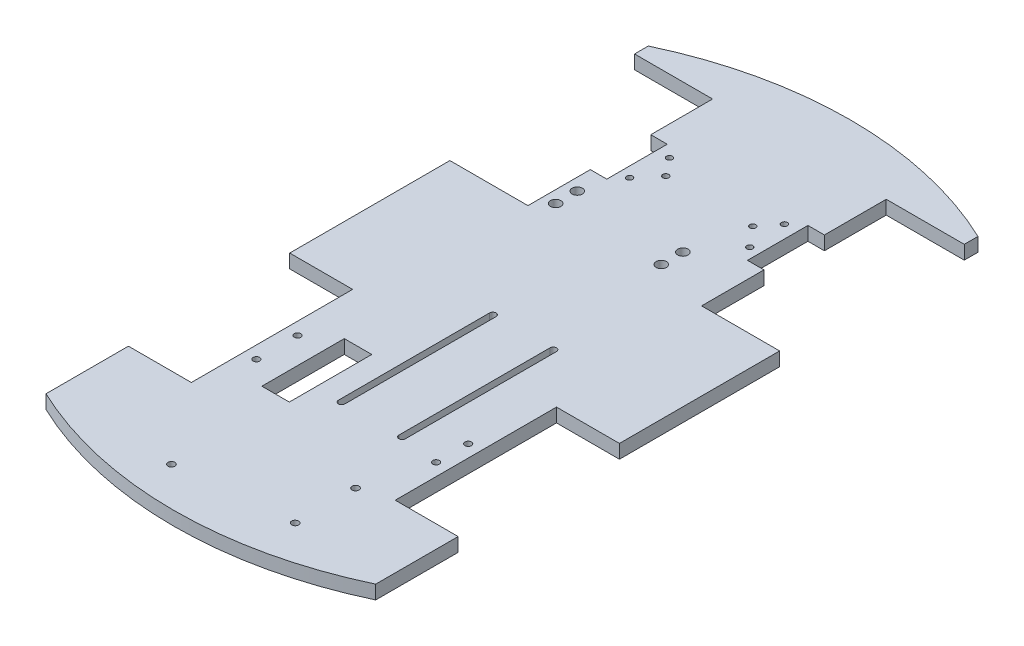
from build123d import *

# Parameters (mm, degrees)
CHASSIS_DEPTH       = 6.35
BOSS_EXTRUDE1_DEPTH = 6.35
SKETCH2_R           = 1.5875
SKETCH2_R_2         = 1.5
SKETCH2_R_3         = 1.3716
SKETCH2_R_4         = 2.38125
SKETCH2_W           = 12.7
SKETCH2_H           = 38.1
CUT_EXTRUDE1_DEPTH  = 17.78


with BuildPart() as part:
    # Sketch1 → Chassis (new body)
    with BuildSketch(Plane(origin=(0, 0, 0), x_dir=(1, 0, 0), z_dir=(0, 1, 0))):
        with BuildLine():
            Line((0, 66.173750115), (0, -229.362))
            Line((0, -229.362), (76.2, -229.362))
            Line((76.2, -229.362), (76.2, -191.262))
            Line((76.2, -191.262), (47.117, -191.262))
            Line((47.117, -191.262), (47.117, -116.713))
            Line((47.117, -116.713), (76.2, -116.713))
            Line((76.2, -116.713), (76.2, -42.672))
            Line((76.2, -42.672), (40.132, -42.672))
            Line((40.132, -42.672), (40.132, -13.843))
            Line((40.132, -13.843), (32.512, -13.843))
            Line((32.512, -13.843), (32.512, 14.097))
            Line((32.512, 14.097), (40.132, 14.097))
            Line((40.132, 14.097), (40.132, 42.672))
            Line((40.132, 42.672), (76.2, 42.672))
            Line((76.2, 42.672), (76.2, 49.022))
            ThreePointArc((76.2, 49.022), (39.053241005, 61.832834411), (0, 66.173750115))
        make_face()
    chassis = extrude(amount=CHASSIS_DEPTH)

    # Mirror1: Chassis across plane
    add(chassis.mirror(Plane(origin=(0, 6.35, 0), x_dir=(0, 0, 1), z_dir=(1, 0, 0))))

    # Sketch4 → Boss-Extrude1 (add)
    with BuildSketch(Plane(origin=(0, 6.35, 0), x_dir=(1, 0, 0), z_dir=(0, 1, 0))):
        with BuildLine():
            Line((76.2, -229.362), (-76.2, -229.362))
            ThreePointArc((-76.2, -229.362), (0, -246.518294863), (76.2, -229.362))
        make_face()
    extrude(amount=-BOSS_EXTRUDE1_DEPTH)

    # Sketch2 → Cut-Extrude1 (cut)
    with BuildSketch(Plane(origin=(0, 0, 0), x_dir=(1, 0, 0), z_dir=(0, 1, 0))):
        with Locations((33.096859047, -195.58)):
            Circle(SKETCH2_R)
        with Locations((-18.973140953, -228.6)):
            Circle(SKETCH2_R)
        with Locations((33.096859047, -223.52)):
            Circle(SKETCH2_R)
        with Locations((41.402, -151.796334461)):
            Circle(SKETCH2_R_2)
        with Locations((-26.555704526, 9.169971692)):
            Circle(SKETCH2_R_3)
        with Locations((-20.105647723, 0.999384842)):
            Circle(SKETCH2_R_3)
        with Locations((-27.786476371, -8.040568412)):
            Circle(SKETCH2_R_3)
        with Locations((26.555704526, 9.169971692)):
            Circle(SKETCH2_R_3)
        with Locations((20.105647723, 0.999384842)):
            Circle(SKETCH2_R_3)
        with Locations((27.786476371, -8.040568412)):
            Circle(SKETCH2_R_3)
        with Locations((14.2672, -25.46003476)):
            Circle(SKETCH2_R_4)
        with Locations((14.2672, -35.42953476)):
            Circle(SKETCH2_R_4)
        with Locations((-34.5516, -25.46003476)):
            Circle(SKETCH2_R_4)
        with Locations((-34.5516, -35.42953476)):
            Circle(SKETCH2_R_4)
        with Locations((-41.402, -147.875000023)):
            Circle(SKETCH2_R_2)
        with Locations((-41.402, -166.925000023)):
            Circle(SKETCH2_R_2)
        with Locations((41.402, -166.655334461)):
            Circle(SKETCH2_R_2)
        with BuildLine():
            Line((24.892, -94.488), (24.892, -164.338))
            ThreePointArc((24.892, -164.338), (23.392, -165.838), (21.892, -164.338))
            Line((21.892, -164.338), (21.892, -94.488))
            ThreePointArc((21.892, -94.488), (23.392, -92.988), (24.892, -94.488))
        make_face()
        with BuildLine():
            Line((-3.048, -94.488), (-3.048, -164.338))
            ThreePointArc((-3.048, -164.338), (-4.548, -165.838), (-6.048, -164.338))
            Line((-6.048, -164.338), (-6.048, -94.488))
            ThreePointArc((-6.048, -94.488), (-4.548, -92.988), (-3.048, -94.488))
        make_face()
        with Locations((-22.987, -157.400000023)):
            Rectangle(SKETCH2_W, SKETCH2_H)
    extrude(amount=CUT_EXTRUDE1_DEPTH, mode=Mode.SUBTRACT)


solid = part.part
